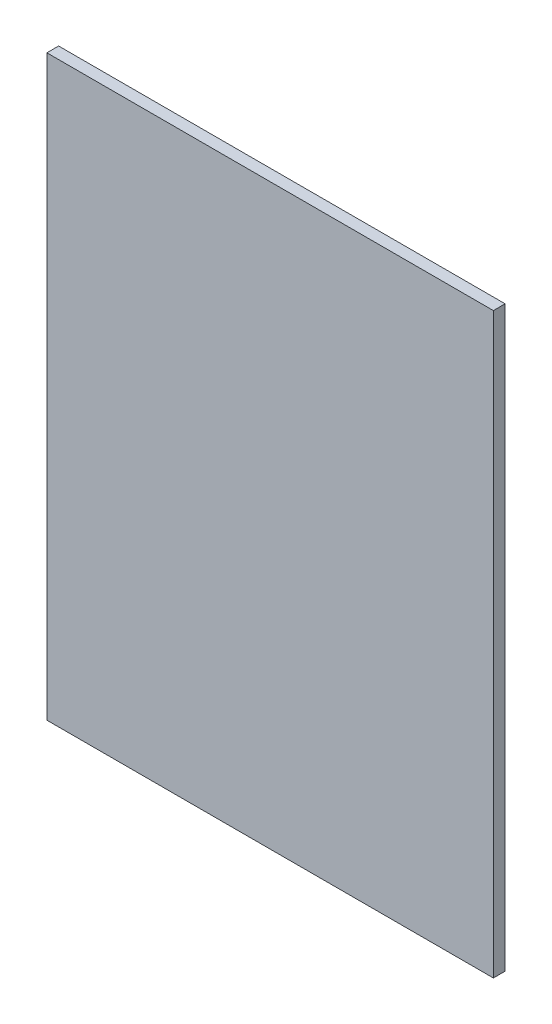
from build123d import *

# Parameters (mm, degrees)
SKETCH1_W           = 96.52
SKETCH1_H           = 124.945454795
BOSS_EXTRUDE1_DEPTH = 2.54


with BuildPart() as part:
    # Sketch1 → Boss-Extrude1 (new body)
    with BuildSketch(Plane.XY):
        with Locations((-17.025523033, -15.219849195)):
            Rectangle(SKETCH1_W, SKETCH1_H)
    extrude(amount=BOSS_EXTRUDE1_DEPTH)


solid = part.part
